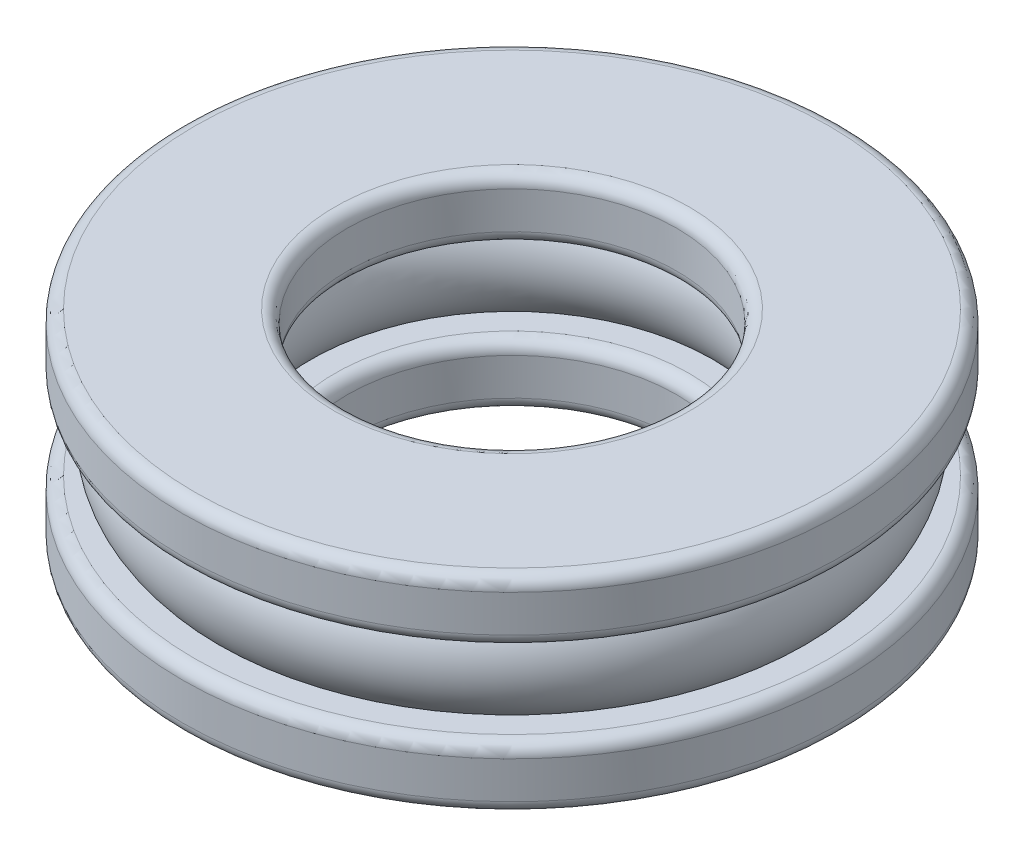
from build123d import *

# Parameters (mm, degrees)
FILLET_1_R = 0.3


with BuildPart() as part:
    # 草图1 → 旋转1 (revolve)
    with BuildSketch(Plane.XY):
        with BuildLine():
            Line((4, 0), (8, 0))
            Line((8, 0), (8, 1.5))
            Line((8, 1.5), (7.118033989, 1.5))
            ThreePointArc((7.118033989, 1.5), (7.5, 2.5), (7.118033989, 3.5))
            Line((7.118033989, 3.5), (8, 3.5))
            Line((8, 3.5), (8, 5))
            Line((8, 5), (4, 5))
            Line((4, 5), (4, 3.5))
            Line((4, 3.5), (4.881966011, 3.5))
            ThreePointArc((4.881966011, 3.5), (4.5, 2.5), (4.881966011, 1.5))
            Line((4.881966011, 1.5), (4, 1.5))
            Line((4, 1.5), (4, 0))
        make_face()
    revolve(axis=Axis((0, 6.967032967, 0), (0, -1, 0)))

    # 圆角1
    fillet_1_edges = [part.edges().sort_by_distance(p)[0] for p in [
        (-4, 3.5, 0),
        (-4, 5, 0),
        (-8, 5, 0),
        (-8, 3.5, 0),
        (-8, 1.5, 0),
        (-8, 0, 0),
        (-4, 0, 0),
        (-4, 1.5, 0),
    ]]
    fillet(fillet_1_edges, radius=FILLET_1_R)


solid = part.part
